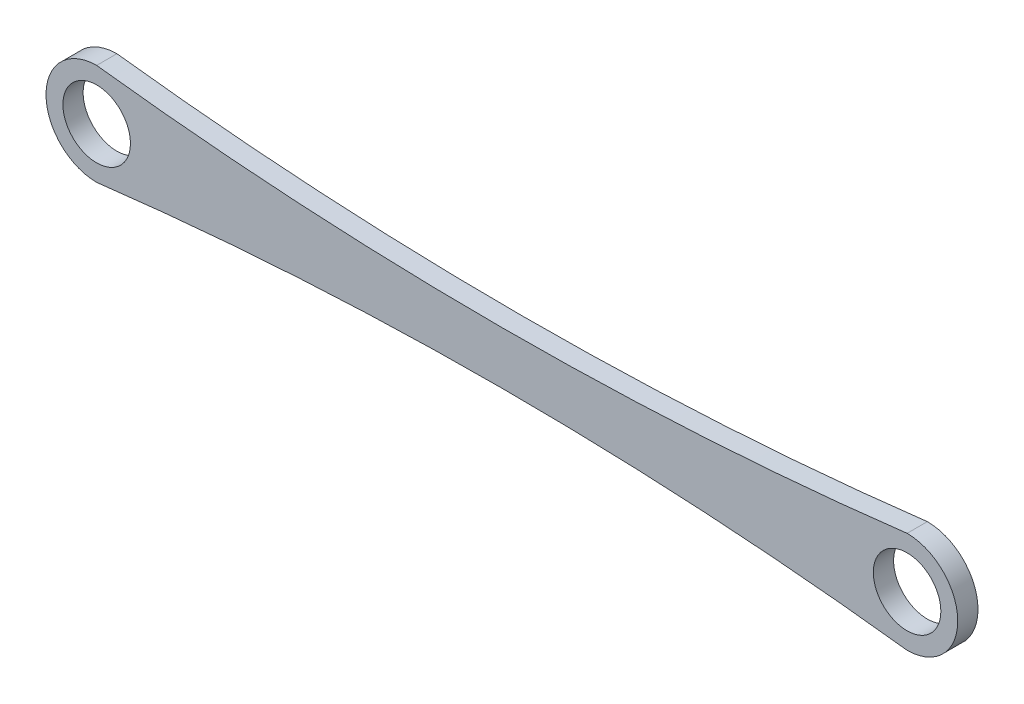
from build123d import *

# Parameters (mm, degrees)
SKETCH1_R           = 5
BOSS_EXTRUDE1_DEPTH = 3


with BuildPart() as part:
    # Sketch1 → Boss-Extrude1 (new body)
    with BuildSketch(Plane.XY):
        with BuildLine():
            ThreePointArc((0, 7.5), (-7.5, 0), (0, -7.5))
            ThreePointArc((0, -7.5), (60, -3.88694584), (120, -7.5))
            ThreePointArc((120, -7.5), (127.5, 0), (120, 7.5))
            ThreePointArc((120, 7.5), (60, 3.88694584), (0, 7.5))
        make_face()
        Circle(SKETCH1_R, mode=Mode.SUBTRACT)
        with Locations((120, 0)):
            Circle(SKETCH1_R, mode=Mode.SUBTRACT)
    extrude(amount=BOSS_EXTRUDE1_DEPTH)


solid = part.part
